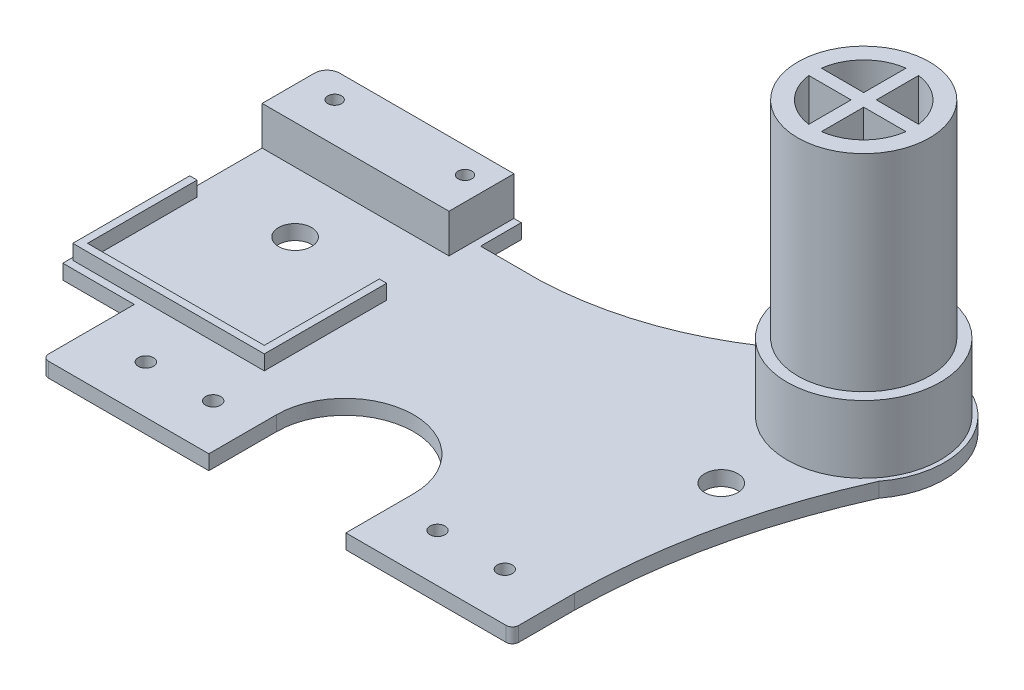
from build123d import *

# Parameters (mm, degrees)
BOSS_EXTRUDE1_DEPTH  = 3.5
SKETCH2_R            = 1.8
SKETCH2_R_2          = 3.920136022
CUT_EXTRUDE1_DEPTH   = 4
SKETCH3_R            = 15
BOSS_EXTRUDE2_DEPTH  = 3.5
SKETCH4_R            = 15
BOSS_EXTRUDE3_DEPTH  = 65
CUT_EXTRUDE2_DEPTH   = 45
BOSS_EXTRUDE4_DEPTH  = 3.5
SKETCH8_R            = 18.202220901
BOSS_EXTRUDE5_DEPTH  = 16
SKETCH9_R            = 15.776157057
SKETCH9_R_2          = 14
CUT_EXTRUDE3_DEPTH   = 49
BOSS_EXTRUDE6_DEPTH  = 3.5
BOSS_EXTRUDE7_DEPTH  = 3.5
SKETCH13_W           = 46.127934492
SKETCH13_H           = 9.661927398
BOSS_EXTRUDE8_DEPTH  = 3.5
SKETCH14_W           = 44.39062698
SKETCH14_H           = 15.435
BOSS_EXTRUDE9_DEPTH  = 9.2
CUT_EXTRUDE4_REACH   = 14.7
SKETCH15_R           = 1.625
FILLET3_R            = 3
SKETCH16_R           = 15.65
SKETCH16_R_2         = 14
BOSS_EXTRUDE10_DEPTH = 49


with BuildPart() as part:
    # Sketch1 → Boss-Extrude1 (new body)
    with BuildSketch(Plane(origin=(0, 0, 0), x_dir=(1, 0, 0), z_dir=(0, 1, 0))):
        with BuildLine():
            Line((-55.85, 37.5), (55.85, 37.5))
            Line((55.85, 37.5), (55.85, -36))
            ThreePointArc((55.85, -36), (55.410660172, -37.060660172), (54.35, -37.5))
            Line((54.35, -37.5), (-54.35, -37.5))
            ThreePointArc((-54.35, -37.5), (-55.410660172, -37.060660172), (-55.85, -36))
            Line((-55.85, -36), (-55.85, 37.5))
        make_face()
    extrude(amount=BOSS_EXTRUDE1_DEPTH)

    # Sketch2 → Cut-Extrude1 (cut)
    with BuildSketch(Plane(origin=(0, 3.5, 0), x_dir=(1, 0, 0), z_dir=(0, 1, 0))):
        with Locations((-42.65, -26.10257403)):
            Circle(SKETCH2_R)
        with Locations((-26.65, -26.10257403)):
            Circle(SKETCH2_R)
        with Locations((26.65, -26.10257403)):
            Circle(SKETCH2_R)
        with Locations((42.65, -26.10257403)):
            Circle(SKETCH2_R)
        with Locations((-50.62881184, 17.336768313)):
            Circle(SKETCH2_R_2)
        with Locations((50.62881184, 17.336768313)):
            Circle(SKETCH2_R_2)
        with BuildLine():
            Line((-16.275049205, -37.5), (-16.275049205, -21.409694211))
            ThreePointArc((-16.275049205, -21.409694211), (0, -5.134645006), (16.275049205, -21.409694211))
            Line((16.275049205, -21.409694211), (16.275049205, -37.5))
            Line((16.275049205, -37.5), (-16.275049205, -37.5))
        make_face()
    extrude(amount=-CUT_EXTRUDE1_DEPTH, mode=Mode.SUBTRACT)

    # Sketch3 → Boss-Extrude2 (add)
    with BuildSketch(Plane(origin=(0, 0, 0), x_dir=(1, 0, 0), z_dir=(0, 1, 0))):
        with Locations((53.706623558, 48.104964972)):
            Circle(SKETCH3_R)
    extrude(amount=BOSS_EXTRUDE2_DEPTH)

    # Sketch4 → Boss-Extrude3 (add)
    with BuildSketch(Plane(origin=(0, 3.5, 0), x_dir=(1, 0, 0), z_dir=(0, 1, 0))):
        with Locations((53.706623558, 48.104964972)):
            Circle(SKETCH4_R)
    extrude(amount=BOSS_EXTRUDE3_DEPTH)

    # Sketch5 → Cut-Extrude2 (cut)
    with BuildSketch(Plane(origin=(0, 68.5, 0), x_dir=(1, 0, 0), z_dir=(0, 1, 0))):
        with BuildLine():
            Line((42.161722237, 46.604964972), (52.206623558, 46.604964972))
            Line((52.206623558, 46.604964972), (52.206623558, 36.560063651))
            ThreePointArc((52.206623558, 36.560063651), (45.474529459, 39.872870873), (42.161722237, 46.604964972))
        make_face()
        with BuildLine():
            Line((65.251524879, 46.604964972), (55.206623558, 46.604964972))
            Line((55.206623558, 46.604964972), (55.206623558, 36.560063651))
            ThreePointArc((55.206623558, 36.560063651), (61.938717657, 39.872870873), (65.251524879, 46.604964972))
        make_face()
        with BuildLine():
            Line((55.206623558, 49.604964972), (65.251524879, 49.604964972))
            ThreePointArc((65.251524879, 49.604964972), (61.938717657, 56.337059071), (55.206623558, 59.649866293))
            Line((55.206623558, 59.649866293), (55.206623558, 49.604964972))
        make_face()
        with BuildLine():
            Line((52.206623558, 59.649866293), (52.206623558, 49.604964972))
            Line((52.206623558, 49.604964972), (42.161722237, 49.604964972))
            ThreePointArc((42.161722237, 49.604964972), (45.474529459, 56.337059071), (52.206623558, 59.649866293))
        make_face()
    extrude(amount=-CUT_EXTRUDE2_DEPTH, mode=Mode.SUBTRACT)

    # Sketch7 → Boss-Extrude4 (add)
    with BuildSketch(Plane(origin=(0, 0, 0), x_dir=(1, 0, 0), z_dir=(0, 1, 0))):
        with BuildLine():
            Line((-12.477353441, 37.5), (55.85, 37.5))
            Line((55.85, 37.5), (55.85, -22.727213829))
            ThreePointArc((55.85, -22.727213829), (59.401653411, 7.516004094), (68.962444737, 36.427208523))
            ThreePointArc((68.962444737, 36.427208523), (65.011720609, 63.638955321), (37.903565045, 59.030779228))
            ThreePointArc((37.903565045, 59.030779228), (14.699548646, 43.617215299), (-12.477353441, 37.5))
        make_face()
    extrude(amount=BOSS_EXTRUDE4_DEPTH)

    # Sketch8 → Boss-Extrude5 (add)
    with BuildSketch(Plane(origin=(0, 3.5, 0), x_dir=(1, 0, 0), z_dir=(0, 1, 0))):
        with Locations((53.706623558, 48.104964972)):
            Circle(SKETCH8_R)
    extrude(amount=BOSS_EXTRUDE5_DEPTH)

    # Sketch9 → Cut-Extrude3 (cut)
    with BuildSketch(Plane(origin=(0, 68.5, 0), x_dir=(1, 0, 0), z_dir=(0, 1, 0))):
        with Locations((53.706623558, 48.104964972)):
            Circle(SKETCH9_R)
        with Locations((53.706623558, 48.104964972)):
            Circle(SKETCH9_R_2, mode=Mode.SUBTRACT)
    extrude(amount=-CUT_EXTRUDE3_DEPTH, mode=Mode.SUBTRACT)

    # Sketch11 → Boss-Extrude6 (add)
    with BuildSketch(Plane(origin=(0, 0, 0), x_dir=(1, 0, 0), z_dir=(0, 1, 0))):
        Polygon((-55.85, 37.5), (-67.841357128, 37.5), (-72.841357128, 37.5), (-72.841357128, 32.5), (-72.841357128, -9.63182819), (-72.841357128, -15.63182819), (-66.841357128, -15.63182819), (-55.85, -15.63182819), (-55.85, -14.63182819), (-55.85, 0), align=None)
    extrude(amount=BOSS_EXTRUDE6_DEPTH)

    # Sketch12 → Boss-Extrude7 (add)
    with BuildSketch(Plane(origin=(0, 3.5, 0), x_dir=(1, 0, 0), z_dir=(0, 1, 0))):
        Polygon((-28.491357128, 15.210034265), (-26.741357128, 15.210034265), (-26.741357128, -13.861045819), (-72.241357128, -13.861045819), (-72.241357128, 13.92894421), (-71.491357128, 13.92894421), (-70.491357128, 13.92894421), (-70.491357128, -12.111045819), (-28.491357128, -12.111045819), align=None)
    extrude(amount=BOSS_EXTRUDE7_DEPTH)

    # Sketch13 → Boss-Extrude8 (add)
    with BuildSketch(Plane(origin=(0, 0, 0), x_dir=(1, 0, 0), z_dir=(0, 1, 0))):
        with Locations((-49.777389882, 42.330963699)):
            Rectangle(SKETCH13_W, SKETCH13_H)
    extrude(amount=BOSS_EXTRUDE8_DEPTH)

    # Sketch14 → Boss-Extrude9 (add)
    with BuildSketch(Plane(origin=(0, 3.5, 0), x_dir=(1, 0, 0), z_dir=(0, 1, 0))):
        with Locations((-50.646043638, 39.444427398)):
            Rectangle(SKETCH14_W, SKETCH14_H)
    extrude(amount=BOSS_EXTRUDE9_DEPTH)

    # Sketch15 → Cut-Extrude4 (cut, up to next)
    with BuildSketch(Plane(origin=(0, 12.7, 0), x_dir=(1, 0, 0), z_dir=(0, 1, 0)), mode=Mode.PRIVATE) as cut_extrude4_sk1:
        with Locations((-64.966357128, 41.090370398)):
            Circle(SKETCH15_R)
    cut_extrude4_tool1 = extrude(cut_extrude4_sk1.sketch, amount=-CUT_EXTRUDE4_REACH, mode=Mode.PRIVATE) & part.part
    add(cut_extrude4_tool1.solids().sort_by_distance((-64.966357, 12.7, -41.09037))[0], mode=Mode.SUBTRACT)
    # Sketch15 → Cut-Extrude4 (cut, up to next)
    with BuildSketch(Plane(origin=(0, 12.7, 0), x_dir=(1, 0, 0), z_dir=(0, 1, 0)), mode=Mode.PRIVATE) as cut_extrude4_sk2:
        with Locations((-34.016357128, 41.090370398)):
            Circle(SKETCH15_R)
    cut_extrude4_tool2 = extrude(cut_extrude4_sk2.sketch, amount=-CUT_EXTRUDE4_REACH, mode=Mode.PRIVATE) & part.part
    add(cut_extrude4_tool2.solids().sort_by_distance((-34.016357, 12.7, -41.09037))[0], mode=Mode.SUBTRACT)

    # Fillet3
    fillet3_edges = [part.edges().sort_by_distance(p)[0] for p in [
        (-72.841357128, 6.35, -47.161927398),
    ]]
    fillet(fillet3_edges, radius=FILLET3_R)

    # Sketch16 → Boss-Extrude10 (add)
    with BuildSketch(Plane(origin=(0, 19.5, 0), x_dir=(1, 0, 0), z_dir=(0, 1, 0))):
        with Locations((53.706623558, 48.104964972)):
            Circle(SKETCH16_R)
        with Locations((53.706623558, 48.104964972)):
            Circle(SKETCH16_R_2, mode=Mode.SUBTRACT)
    extrude(amount=BOSS_EXTRUDE10_DEPTH)


solid = part.part
